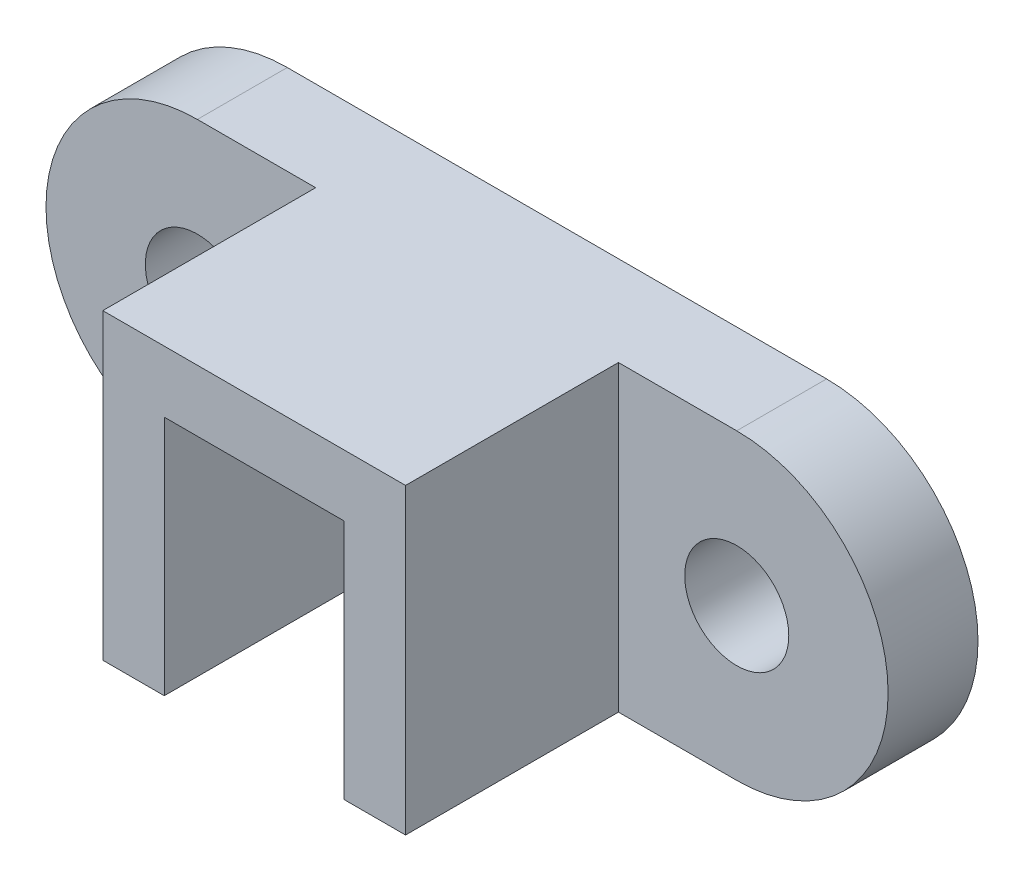
from build123d import *

# Parameters (mm, degrees)
SKETCH1_R           = 11
BOSS_EXTRUDE1_DEPTH = 19
SKETCH3_W           = 64
SKETCH3_H           = 64
BOSS_EXTRUDE2_DEPTH = 45
CUT_EXTRUDE9_DEPTH  = 45
SKETCH6_W           = 38
SKETCH6_H           = 6
CUT_EXTRUDE10_DEPTH = 51
BOSS_EXTRUDE3_DEPTH = 38


with BuildPart() as part:
    # Sketch1 → Boss-Extrude1 (new body)
    with BuildSketch(Plane.XY):
        with BuildLine():
            Line((0, -32), (114, -32))
            ThreePointArc((114, -32), (146, 0), (114, 32))
            Line((114, 32), (0, 32))
            ThreePointArc((0, 32), (-32, 0), (0, -32))
        make_face()
        Circle(SKETCH1_R, mode=Mode.SUBTRACT)
        with Locations((114, 0)):
            Circle(SKETCH1_R, mode=Mode.SUBTRACT)
    extrude(amount=BOSS_EXTRUDE1_DEPTH)

    # Sketch3 → Boss-Extrude2 (add)
    with BuildSketch(Plane.XY.offset(19)):
        with Locations((57, 0)):
            Rectangle(SKETCH3_W, SKETCH3_H)
    extrude(amount=BOSS_EXTRUDE2_DEPTH)

    # Sketch5 → Cut-Extrude9 (cut)
    with BuildSketch(Plane.XY.offset(64)):
        Polygon((38, 19), (76, 19), (76, -32), (57, -32), (38, -32), align=None)
    extrude(amount=-CUT_EXTRUDE9_DEPTH, mode=Mode.SUBTRACT)

    # Sketch6 → Cut-Extrude10 (cut)
    with BuildSketch(Plane.XZ.offset(32)):
        with Locations((57, 16)):
            Rectangle(SKETCH6_W, SKETCH6_H)
    extrude(amount=-CUT_EXTRUDE10_DEPTH, mode=Mode.SUBTRACT)

    # Sketch7 → Boss-Extrude3 (add)
    with BuildSketch(Plane(origin=(38, 0, 0), x_dir=(0, 0, -1), z_dir=(1, 0, 0))):
        Polygon((-64, 19), (-13, -32), (-13, 19), align=None)
    extrude(amount=BOSS_EXTRUDE3_DEPTH)


solid = part.part
